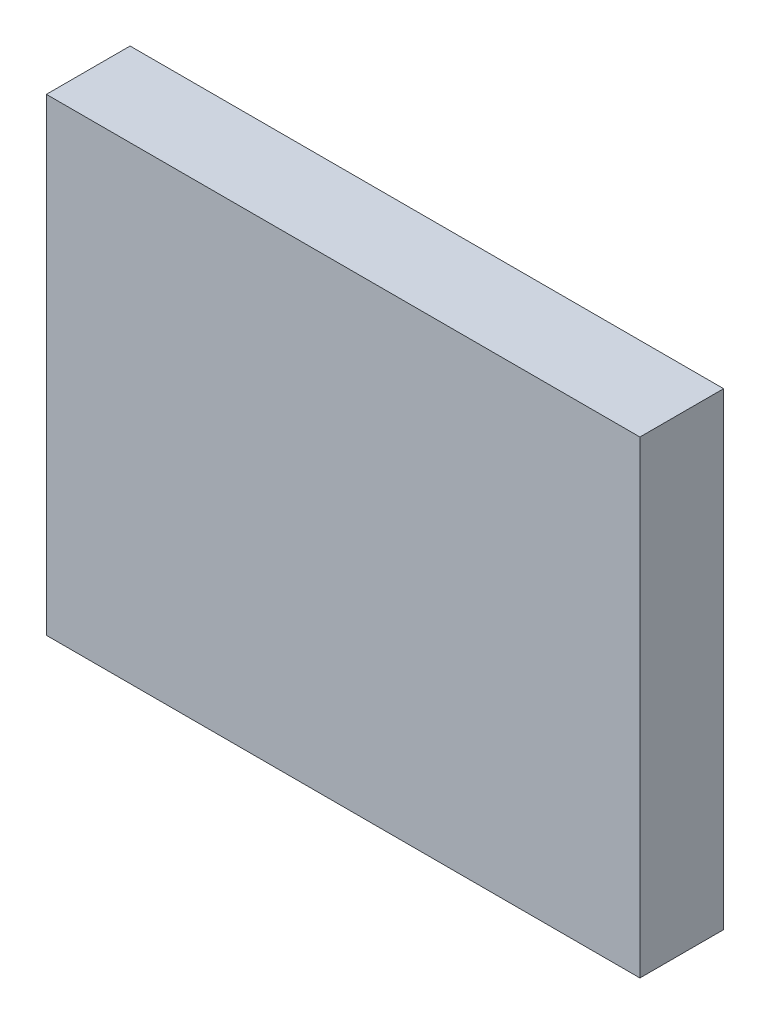
from build123d import *

# Parameters (mm, degrees)
SKIZZE1_W                       = 70.905276948
SKIZZE1_H                       = 55.970788825
AUFSATZ_LINEAR_AUSTRAGEN1_DEPTH = 10


with BuildPart() as part:
    # Skizze1 → Aufsatz-Linear austragen1 (new body)
    with BuildSketch(Plane.XY):
        with Locations((-35.452638474, 27.985394413)):
            Rectangle(SKIZZE1_W, SKIZZE1_H)
    extrude(amount=AUFSATZ_LINEAR_AUSTRAGEN1_DEPTH)


solid = part.part
